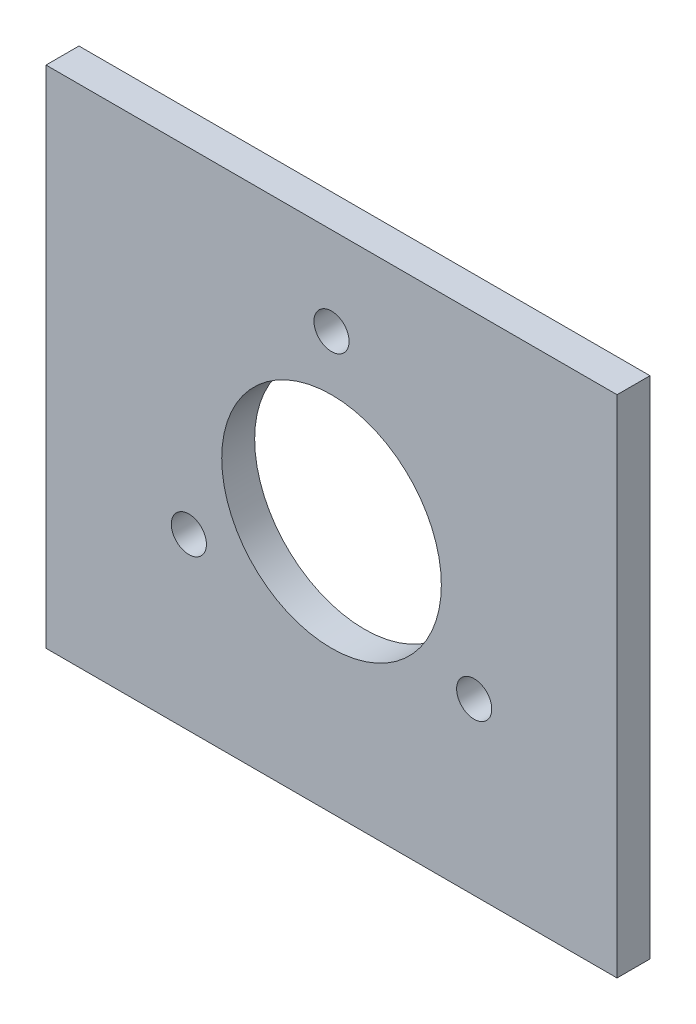
from build123d import *

# Parameters (mm, degrees)
SKETCH_1_W          = 52
SKETCH_1_H          = 46
EXTRUDE_1_DEPTH     = 3
SKETCH_2_R          = 10
SKETCH_2_R_2        = 1.6
CUT_EXTRUDE_1_DEPTH = 4


with BuildPart() as part:
    # 草图1 → 凸台-拉伸1 (new body)
    with BuildSketch(Plane.XY):
        Rectangle(SKETCH_1_W, SKETCH_1_H)
    extrude(amount=EXTRUDE_1_DEPTH)

    # 草图2 → 切除-拉伸1 (cut, through all)
    with BuildSketch(Plane.XY.offset(3)):
        Circle(SKETCH_2_R)
        with Locations((0, 15)):
            Circle(SKETCH_2_R_2)
        with Locations((12.990381057, -7.5)):
            Circle(SKETCH_2_R_2)
        with Locations((-12.990381057, -7.5)):
            Circle(SKETCH_2_R_2)
    extrude(amount=-CUT_EXTRUDE_1_DEPTH, mode=Mode.SUBTRACT)


solid = part.part
